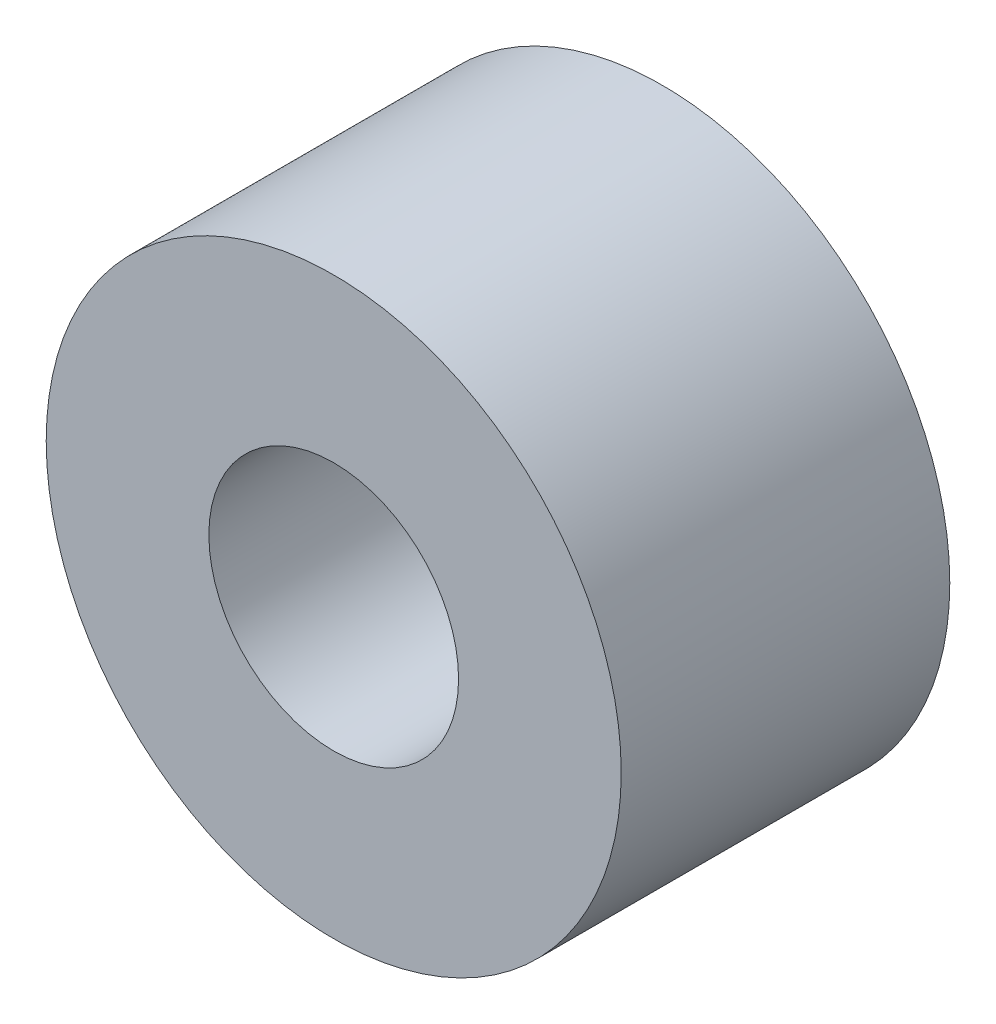
from build123d import *

# Parameters (mm, degrees)
SKETCH1_R           = 5.55625
BOSS_EXTRUDE1_DEPTH = 3.175
SKETCH2_R           = 2.413
CUT_EXTRUDE1_DEPTH  = 7.35


with BuildPart() as part:
    # Sketch1 → Boss-Extrude1 (new body, symmetric)
    with BuildSketch(Plane.XY):
        Circle(SKETCH1_R)
    extrude(amount=BOSS_EXTRUDE1_DEPTH, both=True)

    # Sketch2 → Cut-Extrude1 (cut, through all)
    with BuildSketch(Plane.XY.offset(3.175)):
        Circle(SKETCH2_R)
    extrude(amount=-CUT_EXTRUDE1_DEPTH, mode=Mode.SUBTRACT)


solid = part.part
